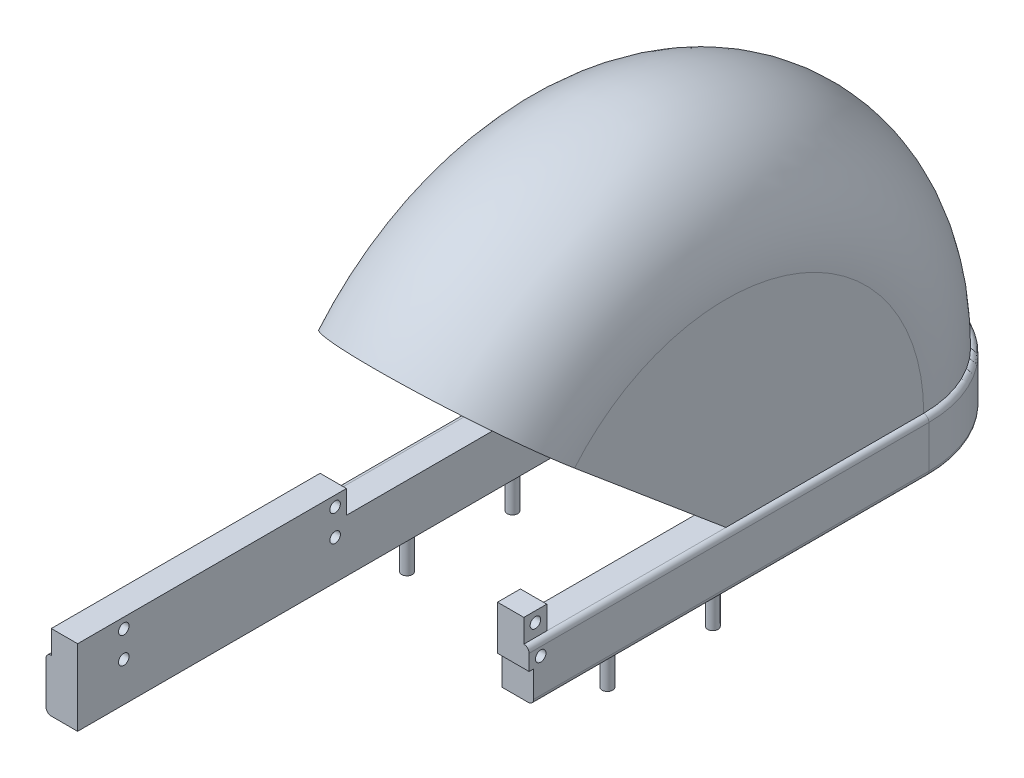
from build123d import *

# Parameters (mm, degrees)
BOSS_EXTRUDE1_DEPTH  = 20
FILLET1_R            = 2
CUT_EXTRUDE3_DEPTH   = 15
REVOLVE1_ANGLE       = 140
CUT_EXTRUDE5_DEPTH   = 20
SKETCH12_R           = 2
BOSS_EXTRUDE3_DEPTH  = 15
SKETCH14_W           = 90
SKETCH14_H           = 51.446942877
CUT_EXTRUDE6_DEPTH   = 10
SKETCH15_R           = 2
BOSS_EXTRUDE4_DEPTH  = 25
SKETCH19_W           = 2
SKETCH19_H           = 5
CUT_EXTRUDE7_DEPTH   = 150
SKETCH21_W           = 90
SKETCH21_H           = 51.374670228
CUT_EXTRUDE9_DEPTH   = 40
CUT_EXTRUDE10_DEPTH  = 20
BOSS_EXTRUDE6_DEPTH  = 1.7
SKETCH28_W           = 10
SKETCH28_H           = 8.8
BOSS_EXTRUDE7_DEPTH  = 7
SKETCH29_W           = 10
SKETCH29_H           = 8.8
BOSS_EXTRUDE8_DEPTH  = 1.7
SKETCH30_R           = 2
CUT_EXTRUDE11_DEPTH  = 89
SKETCH31_W           = 10
SKETCH31_H           = 8.8
BOSS_EXTRUDE9_DEPTH  = 7
SKETCH32_R           = 2
CUT_EXTRUDE12_DEPTH  = 20
SKETCH34_R           = 2
CUT_EXTRUDE13_DEPTH  = 89
SKETCH35_R           = 2
CUT_EXTRUDE14_DEPTH  = 20
BOSS_EXTRUDE10_DEPTH = 95
SKETCH39_R           = 2
CUT_EXTRUDE15_DEPTH  = 80


with BuildPart() as part:
    # Sketch1 → Boss-Extrude1 (new body)
    with BuildSketch(Plane(origin=(0, 0, 0), x_dir=(1, 0, 0), z_dir=(0, 1, 0))):
        with BuildLine():
            Line((0, 0), (0, 150))
            ThreePointArc((0, 150), (-45, 195), (-90, 150))
            Line((-90, 150), (-90, 0))
            ThreePointArc((-90, 0), (-45, -45), (0, 0))
        make_face()
    extrude(amount=-BOSS_EXTRUDE1_DEPTH)

    # Fillet1
    fillet1_edges = [part.edges().sort_by_distance(p)[0] for p in [
        (-45, -20, -195),
        (-90, -20, -75),
        (-45, -20, 45),
        (-90, 0, -75),
        (-45, 0, -195),
        (0, 0, -75),
        (-45, 0, 45),
        (0, -20, -75),
    ]]
    fillet(fillet1_edges, radius=FILLET1_R)

    # Sketch5 → Cut-Extrude3 (cut)
    with BuildSketch(Plane(origin=(0, 0, 0), x_dir=(1, 0, 0), z_dir=(0, 1, 0))):
        with BuildLine():
            Line((-78, 0), (-78, 150))
            ThreePointArc((-78, 150), (-45, 183), (-12, 150))
            Line((-12, 150), (-12, 0))
            ThreePointArc((-12, 0), (-45, -33), (-78, 0))
        make_face()
    extrude(amount=-CUT_EXTRUDE3_DEPTH, mode=Mode.SUBTRACT)

    # Sketch8 → Revolve1 (revolve)
    with BuildSketch(Plane(origin=(0, 0, 0), x_dir=(1, 0, 0), z_dir=(0, 1, 0))):
        with BuildLine():
            Line((-2, 75), (-2, 150))
            ThreePointArc((-2, 150), (-45, 193), (-88, 150))
            Line((-88, 150), (-88, 75))
            Line((-88, 75), (-78, 75))
            Line((-78, 75), (-78, 150))
            ThreePointArc((-78, 150), (-45, 183), (-12, 150))
            Line((-12, 150), (-12, 75))
            Line((-12, 75), (-2, 75))
        make_face()
    revolve(axis=Axis((-12, 0, -75), (1, 0, 0)), revolution_arc=REVOLVE1_ANGLE)

    # Sketch11 → Cut-Extrude5 (cut)
    with BuildSketch(Plane.XZ.offset(20)):
        with BuildLine():
            Line((-76, -150), (-76, 0))
            ThreePointArc((-76, 0), (-45, 31), (-14, 0))
            Line((-14, 0), (-14, -150))
            ThreePointArc((-14, -150), (-45, -181), (-76, -150))
        make_face()
    extrude(amount=-CUT_EXTRUDE5_DEPTH, mode=Mode.SUBTRACT)

    # Sketch12 → Boss-Extrude3 (add)
    with BuildSketch(Plane.XZ.offset(20)):
        with Locations((-83, -75)):
            Circle(SKETCH12_R)
        with Locations((-83, -35)):
            Circle(SKETCH12_R)
        with Locations((-83, 5)):
            Circle(SKETCH12_R)
        with Locations((-7, 5)):
            Circle(SKETCH12_R)
        with Locations((-7, -35)):
            Circle(SKETCH12_R)
        with Locations((-7, -75)):
            Circle(SKETCH12_R)
    extrude(amount=BOSS_EXTRUDE3_DEPTH)

    # Sketch14 → Cut-Extrude6 (cut)
    with BuildSketch(Plane.XZ.offset(20)):
        with Locations((-45, 25.723471439)):
            Rectangle(SKETCH14_W, SKETCH14_H)
    extrude(amount=-CUT_EXTRUDE6_DEPTH, mode=Mode.SUBTRACT)

    # Sketch15 → Boss-Extrude4 (add)
    with BuildSketch(Plane.XZ.offset(35)):
        with Locations((-7, 5)):
            Circle(SKETCH15_R)
        with Locations((-83, 5)):
            Circle(SKETCH15_R)
    extrude(amount=-BOSS_EXTRUDE4_DEPTH)

    # Sketch19 → Cut-Extrude7 (cut)
    with BuildSketch(Plane.XY):
        with Locations((-13, -17.5)):
            Rectangle(SKETCH19_W, SKETCH19_H)
        with Locations((-77, -17.5)):
            Rectangle(SKETCH19_W, SKETCH19_H)
    extrude(amount=-CUT_EXTRUDE7_DEPTH, mode=Mode.SUBTRACT)

    # Sketch21 → Cut-Extrude9 (cut)
    with BuildSketch(Plane(origin=(0, -35, 0), x_dir=(-1, 0, 0), z_dir=(0, -1, 0))):
        with Locations((45, -25.687335114)):
            Rectangle(SKETCH21_W, SKETCH21_H)
    extrude(amount=-CUT_EXTRUDE9_DEPTH, mode=Mode.SUBTRACT)

    # Sketch24 → Cut-Extrude10 (cut)
    with BuildSketch(Plane(origin=(0, -20, 0), x_dir=(-1, 0, 0), z_dir=(0, -1, 0))):
        with BuildLine():
            Line((12, 150), (14, 150))
            ThreePointArc((14, 150), (45, 181), (76, 150))
            Line((76, 150), (78, 150))
            ThreePointArc((78, 150), (45, 183), (12, 150))
        make_face()
    extrude(amount=-CUT_EXTRUDE10_DEPTH, mode=Mode.SUBTRACT)

    # Sketch26 → Boss-Extrude6 (add)
    with BuildSketch(Plane.XY):
        with BuildLine():
            Line((-2, 0), (-12, 0))
            Line((-12, 0), (-12, -8))
            Line((-12, -8), (-2, -8))
            Line((-2, -8), (0, -8))
            Line((0, -8), (0, -2))
            ThreePointArc((0, -2), (-0.585786438, -0.585786438), (-2, 0))
        make_face()
    extrude(amount=BOSS_EXTRUDE6_DEPTH)

    # Sketch28 → Boss-Extrude7 (add)
    with BuildSketch(Plane.XY):
        with Locations((-7, 4.4)):
            Rectangle(SKETCH28_W, SKETCH28_H)
    extrude(amount=-BOSS_EXTRUDE7_DEPTH)

    # Sketch29 → Boss-Extrude8 (add)
    with BuildSketch(Plane.XY):
        with Locations((-7, 4.4)):
            Rectangle(SKETCH29_W, SKETCH29_H)
    extrude(amount=BOSS_EXTRUDE8_DEPTH)

    # Sketch30 → Cut-Extrude11 (cut, through all)
    with BuildSketch(Plane(origin=(-2, 0, 0), x_dir=(0, 0, -1), z_dir=(1, 0, 0))):
        with Locations((2.69, 4.9)):
            Circle(SKETCH30_R)
    extrude(amount=-CUT_EXTRUDE11_DEPTH, mode=Mode.SUBTRACT)

    # Sketch31 → Boss-Extrude9 (add)
    with BuildSketch(Plane.XY):
        with Locations((-83, 4.4)):
            Rectangle(SKETCH31_W, SKETCH31_H)
    extrude(amount=-BOSS_EXTRUDE9_DEPTH)

    # Sketch32 → Cut-Extrude12 (cut)
    with BuildSketch(Plane(origin=(-78, 0, 0), x_dir=(0, 0, -1), z_dir=(1, 0, 0))):
        with Locations((2.69, 4.9)):
            Circle(SKETCH32_R)
    extrude(amount=-CUT_EXTRUDE12_DEPTH, mode=Mode.SUBTRACT)

    # Sketch34 → Cut-Extrude13 (cut, through all)
    with BuildSketch(Plane.ZY.offset(88)):
        with Locations((-2.7, -5.1)):
            Circle(SKETCH34_R)
    extrude(amount=-CUT_EXTRUDE13_DEPTH, mode=Mode.SUBTRACT)

    # Sketch35 → Cut-Extrude14 (cut)
    with BuildSketch(Plane(origin=(-88, 0, 0), x_dir=(0, 0, -1), z_dir=(1, 0, 0))):
        with Locations((2.7, -5.1)):
            Circle(SKETCH35_R)
    extrude(amount=-CUT_EXTRUDE14_DEPTH, mode=Mode.SUBTRACT)

    # Sketch36 → Boss-Extrude10 (add)
    with BuildSketch(Plane.XY):
        with BuildLine():
            Line((-88, -20), (-78, -20))
            Line((-78, -20), (-78, 8.8))
            Line((-78, 8.8), (-88, 8.8))
            Line((-88, 8.8), (-88, 0))
            ThreePointArc((-88, 0), (-89.414213562, -0.585786438), (-90, -2))
            Line((-90, -2), (-90, -18))
            ThreePointArc((-90, -18), (-89.414213562, -19.414213562), (-88, -20))
        make_face()
    extrude(amount=BOSS_EXTRUDE10_DEPTH)

    # Sketch39 → Cut-Extrude15 (cut)
    with BuildSketch(Plane.ZY.offset(90)):
        with Locations((77.5, -5.1)):
            Circle(SKETCH39_R)
        with Locations((77.5, 4.9)):
            Circle(SKETCH39_R)
    extrude(amount=-CUT_EXTRUDE15_DEPTH, mode=Mode.SUBTRACT)


solid = part.part
